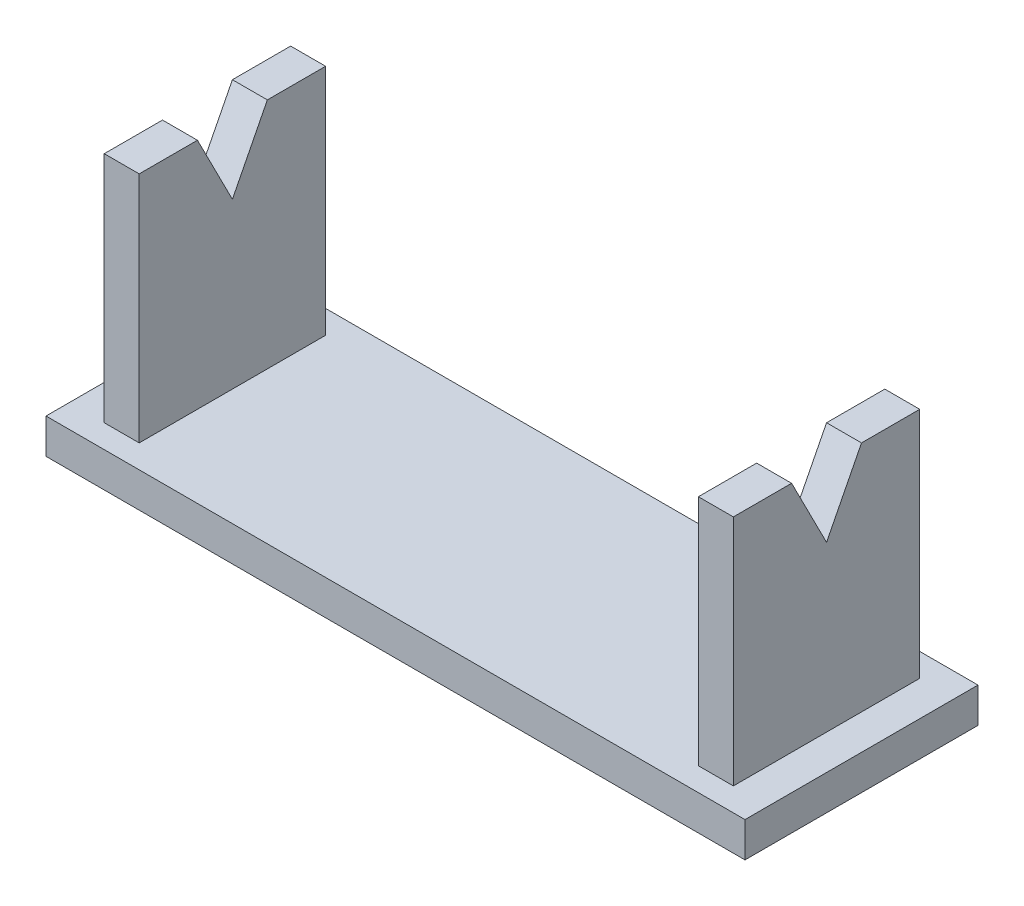
from build123d import *

# Parameters (mm, degrees)
SKETCH_1_W               = 60
SKETCH_1_H               = 20
EXTRUDE_320_DEPTH        = 3
SKETCH_3_W               = 3
SKETCH_3_H               = 16
EXTRUDE_3_DEPTH          = 20
CUT_EXTRUDE_4_DEPTH      = 4
CUT_EXTRUDE_4_DEPTH_BACK = 58


with BuildPart() as part:
    # Эскиз1 → Extrude 320 (new body)
    with BuildSketch(Plane(origin=(0, 0, 0), x_dir=(1, 0, 0), z_dir=(0, 1, 0))):
        with Locations((30, 10)):
            Rectangle(SKETCH_1_W, SKETCH_1_H)
    extrude(amount=EXTRUDE_320_DEPTH)

    # Эскиз3 → Бобышка-Вытянуть3 (add)
    with BuildSketch(Plane(origin=(0, 3, 0), x_dir=(1, 0, 0), z_dir=(0, 1, 0))):
        with Locations((4.5, 10)):
            Rectangle(SKETCH_3_W, SKETCH_3_H)
        with Locations((55.5, 10)):
            Rectangle(SKETCH_3_W, SKETCH_3_H)
    extrude(amount=EXTRUDE_3_DEPTH)

    # Эскиз13 → Вырез-Вытянуть4 (cut, two sides)
    with BuildSketch(Plane(origin=(57, 0, 0), x_dir=(0, 0, -1), z_dir=(1, 0, 0))) as cut_extrude_4_sk:
        Polygon((7, 23), (10, 17.110151736), (13, 23), align=None)
    extrude(amount=CUT_EXTRUDE_4_DEPTH, mode=Mode.SUBTRACT)
    extrude(cut_extrude_4_sk.sketch, amount=-CUT_EXTRUDE_4_DEPTH_BACK, mode=Mode.SUBTRACT)


solid = part.part
